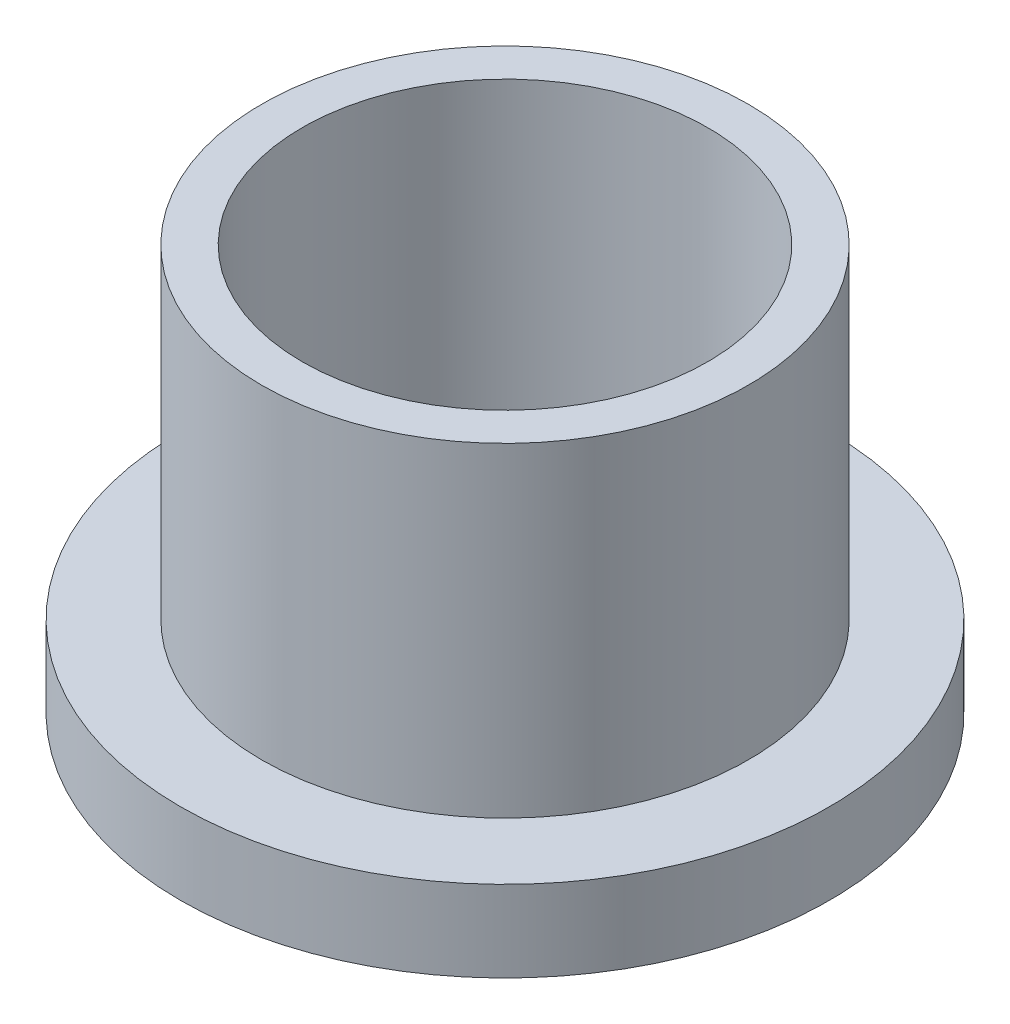
from build123d import *

# Parameters (mm, degrees)
SKETCH2_R           = 9.525
SKETCH2_R_2         = 7.9375
BOSS_EXTRUDE1_DEPTH = 15.875
SKETCH3_R           = 12.7
SKETCH3_R_2         = 9.525
BOSS_EXTRUDE2_DEPTH = 3.175


with BuildPart() as part:
    # Sketch2 → Boss-Extrude1 (new body)
    with BuildSketch(Plane(origin=(0, 0, 0), x_dir=(1, 0, 0), z_dir=(0, 1, 0))):
        Circle(SKETCH2_R)
        Circle(SKETCH2_R_2, mode=Mode.SUBTRACT)
    extrude(amount=BOSS_EXTRUDE1_DEPTH)

    # Sketch3 → Boss-Extrude2 (add)
    with BuildSketch(Plane(origin=(0, 0, 0), x_dir=(1, 0, 0), z_dir=(0, 1, 0))):
        Circle(SKETCH3_R)
        Circle(SKETCH3_R_2, mode=Mode.SUBTRACT)
    extrude(amount=BOSS_EXTRUDE2_DEPTH)


solid = part.part
